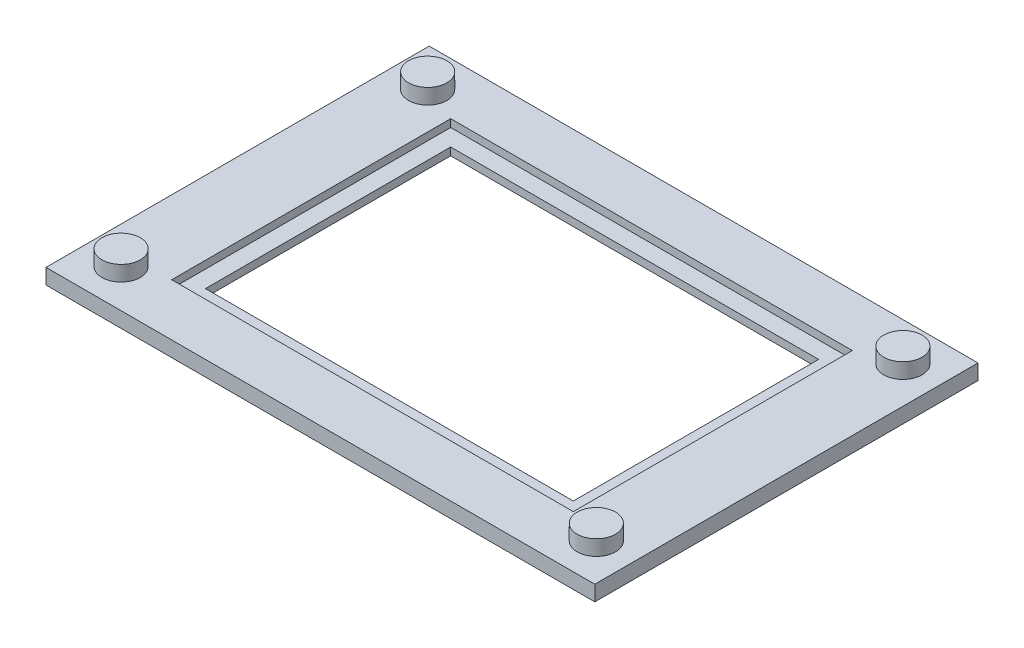
from build123d import *

# Parameters (mm, degrees)
SKETCH1_W           = 35.8
SKETCH1_H           = 25
SKETCH1_W_2         = 24
SKETCH1_H_2         = 16
BOSS_EXTRUDE1_DEPTH = 1
SKETCH2_W           = 26.2
SKETCH2_H           = 18.2
CUT_EXTRUDE1_DEPTH  = 0.5
SKETCH4_R           = 1.25
BOSS_EXTRUDE2_DEPTH = 1


with BuildPart() as part:
    # Sketch1 → Boss-Extrude1 (new body)
    with BuildSketch(Plane(origin=(0, 0, 0), x_dir=(1, 0, 0), z_dir=(0, 1, 0))):
        Rectangle(SKETCH1_W, SKETCH1_H)
        Rectangle(SKETCH1_W_2, SKETCH1_H_2, mode=Mode.SUBTRACT)
    extrude(amount=BOSS_EXTRUDE1_DEPTH)

    # Sketch2 → Cut-Extrude1 (cut)
    with BuildSketch(Plane(origin=(0, 1, 0), x_dir=(1, 0, 0), z_dir=(0, 1, 0))):
        Rectangle(SKETCH2_W, SKETCH2_H)
    extrude(amount=-CUT_EXTRUDE1_DEPTH, mode=Mode.SUBTRACT)

    # Sketch4 → Boss-Extrude2 (add)
    with BuildSketch(Plane(origin=(0, 1, 0), x_dir=(1, 0, 0), z_dir=(0, 1, 0))):
        with Locations((-15.5, 10)):
            Circle(SKETCH4_R)
        with Locations((-15.5, -10)):
            Circle(SKETCH4_R)
        with Locations((15.5, -10)):
            Circle(SKETCH4_R)
        with Locations((15.5, 10)):
            Circle(SKETCH4_R)
    extrude(amount=BOSS_EXTRUDE2_DEPTH)


solid = part.part
